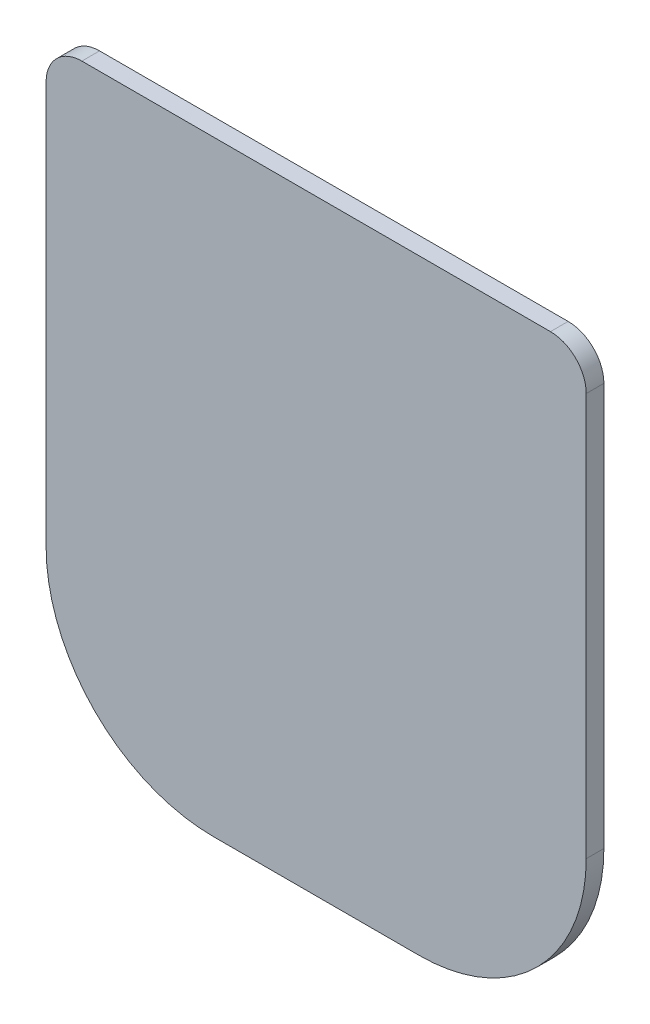
from build123d import *

# Parameters (mm, degrees)
BOSS_EXTRUDE1_DEPTH = 4.3


with BuildPart() as part:
    # Sketch1 → Boss-Extrude1 (new body)
    with BuildSketch(Plane.XY):
        with BuildLine():
            Line((-65.7, 58.81), (-65.7, -39.19))
            ThreePointArc((-65.7, -39.19), (-53.779245994, -67.969245994), (-25, -79.89))
            Line((-25, -79.89), (-0.5, -79.89))
            Line((-0.5, -79.89), (0.5, -79.89))
            Line((0.5, -79.89), (25, -79.89))
            ThreePointArc((25, -79.89), (53.779245994, -67.969245994), (65.7, -39.19))
            Line((65.7, -39.19), (65.7, 58.81))
            ThreePointArc((65.7, 58.81), (63.151828996, 64.961828996), (57, 67.51))
            Line((57, 67.51), (-57, 67.51))
            ThreePointArc((-57, 67.51), (-63.151828996, 64.961828996), (-65.7, 58.81))
        make_face()
    extrude(amount=BOSS_EXTRUDE1_DEPTH)


solid = part.part
